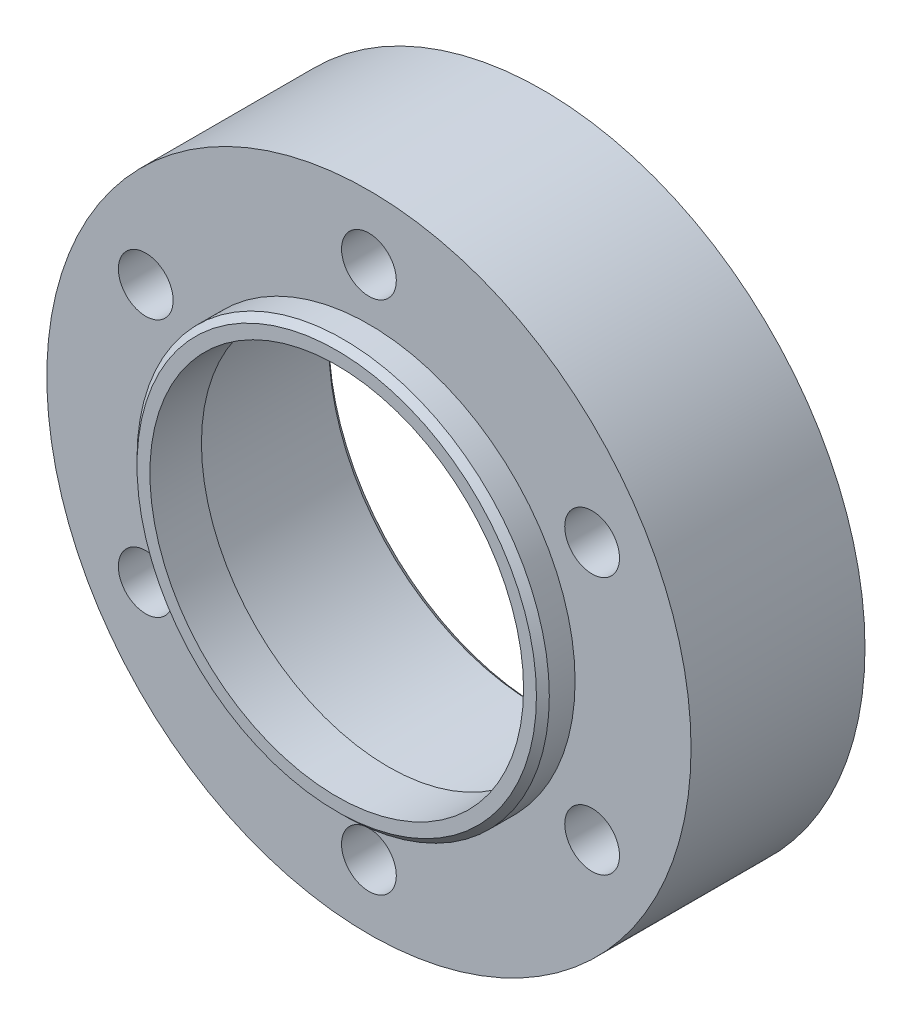
from build123d import *

# Parameters (mm, degrees)
ESQUISSE2_R             = 50
BOSS_EXTRU_1_DEPTH      = 27
ESQUISSE3_R             = 32.2
ENL_V_MAT_EXTRU_1_DEPTH = 24
ESQUISSE4_R             = 32
BOSS_EXTRU_2_DEPTH      = 5
ESQUISSE5_R             = 29
ENL_V_MAT_EXTRU_2_DEPTH = 33
ESQUISSE6_R             = 4.25
ENL_V_MAT_EXTRU_3_DEPTH = 33
CHANFREIN1_SIZE         = 1


with BuildPart() as part:
    # Esquisse2 → Boss.-Extru.1 (new body)
    with BuildSketch(Plane.XY):
        Circle(ESQUISSE2_R)
    extrude(amount=BOSS_EXTRU_1_DEPTH)

    # Esquisse3 → Enlèv. mat.-Extru.1 (cut)
    with BuildSketch(Plane(origin=(0, 0, 0), x_dir=(-1, 0, 0), z_dir=(0, 0, -1))):
        Circle(ESQUISSE3_R)
    extrude(amount=-ENL_V_MAT_EXTRU_1_DEPTH, mode=Mode.SUBTRACT)

    # Esquisse4 → Boss.-Extru.2 (add)
    with BuildSketch(Plane.XY.offset(27)):
        Circle(ESQUISSE4_R)
    extrude(amount=BOSS_EXTRU_2_DEPTH)

    # Esquisse5 → Enlèv. mat.-Extru.2 (cut, through all)
    with BuildSketch(Plane.XY.offset(32)):
        Circle(ESQUISSE5_R)
    extrude(amount=-ENL_V_MAT_EXTRU_2_DEPTH, mode=Mode.SUBTRACT)

    # Esquisse6 → Enlèv. mat.-Extru.3 (cut, through all)
    with BuildSketch(Plane(origin=(0, 0, 0), x_dir=(-1, 0, 0), z_dir=(0, 0, -1))):
        with Locations((0, 40)):
            Circle(ESQUISSE6_R)
        with Locations((34.641016151, 20)):
            Circle(ESQUISSE6_R)
        with Locations((34.641016151, -20)):
            Circle(ESQUISSE6_R)
        with Locations((0, -40)):
            Circle(ESQUISSE6_R)
        with Locations((-34.641016151, -20)):
            Circle(ESQUISSE6_R)
        with Locations((-34.641016151, 20)):
            Circle(ESQUISSE6_R)
    extrude(amount=-ENL_V_MAT_EXTRU_3_DEPTH, mode=Mode.SUBTRACT)

    # Chanfrein1
    chanfrein1_edges = [part.edges().sort_by_distance(p)[0] for p in [
        (-32, 0, 32),
        (32.2, 0, 0),
    ]]
    chamfer(chanfrein1_edges, length=CHANFREIN1_SIZE)


solid = part.part
